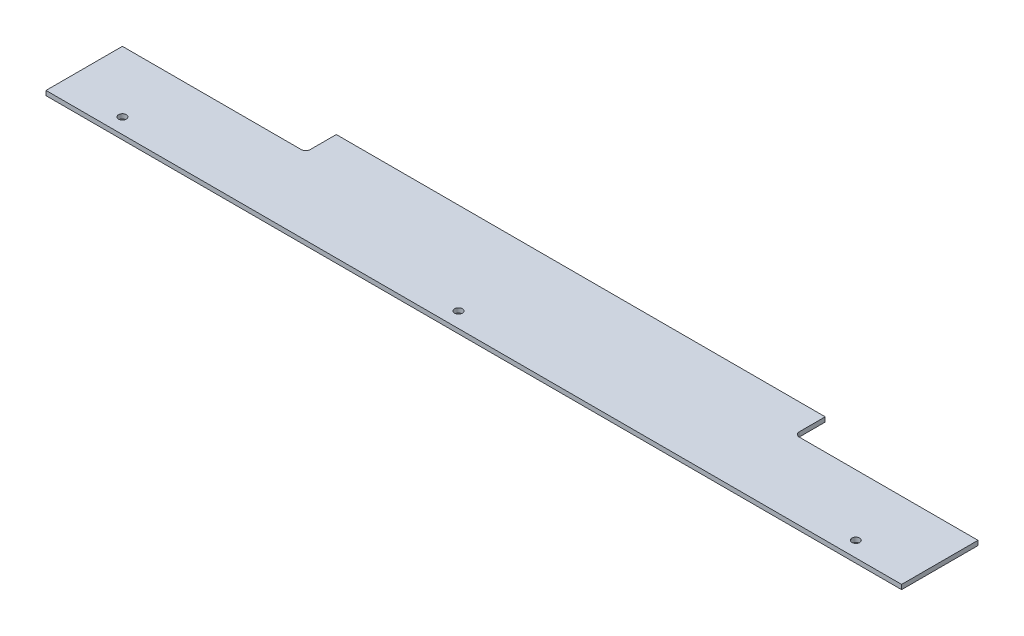
from build123d import *

# Parameters (mm, degrees)
SKETCH1_R           = 2.55
BOSS_EXTRUDE1_DEPTH = 3


with BuildPart() as part:
    # Sketch1 → Boss-Extrude1 (new body)
    with BuildSketch(Plane(origin=(0, 0, 0), x_dir=(1, 0, 0), z_dir=(0, 1, 0))):
        with BuildLine():
            Line((-170, 27.5), (-170, 10.5))
            ThreePointArc((-170, 10.5), (-170.878679656, 8.378679656), (-173, 7.5))
            Line((-173, 7.5), (-290, 7.5))
            Line((-290, 7.5), (-290, -42.5))
            Line((-290, -42.5), (270, -42.5))
            Line((270, -42.5), (270, 7.5))
            Line((270, 7.5), (153, 7.5))
            ThreePointArc((153, 7.5), (150.878679656, 8.378679656), (150, 10.5))
            Line((150, 10.5), (150, 27.5))
            Line((150, 27.5), (-170, 27.5))
        make_face()
        with Locations((-250, -32.5)):
            Circle(SKETCH1_R, mode=Mode.SUBTRACT)
        with Locations((-30, -32.5)):
            Circle(SKETCH1_R, mode=Mode.SUBTRACT)
        with Locations((230, -32.5)):
            Circle(SKETCH1_R, mode=Mode.SUBTRACT)
    extrude(amount=BOSS_EXTRUDE1_DEPTH)


solid = part.part
